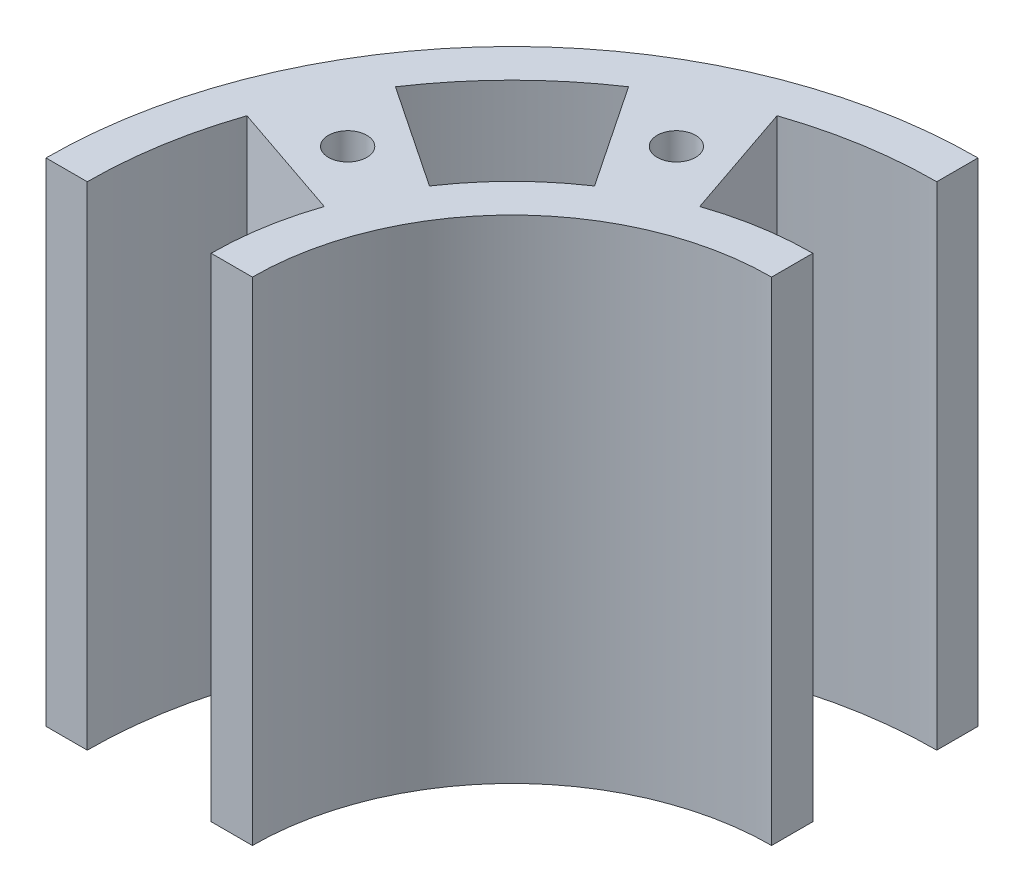
from build123d import *

# Parameters (mm, degrees)
SKETCH2_R           = 1.825
BOSS_EXTRUDE2_DEPTH = 46.8


with BuildPart() as part:
    # Sketch2 → Boss-Extrude2 (new body)
    with BuildSketch(Plane(origin=(0, 0, 0), x_dir=(1, 0, 0), z_dir=(0, 1, 0))):
        with BuildLine():
            Line((31.4, -60), (35.32, -60))
            ThreePointArc((35.32, -60), (42.54860464, -42.54860464), (60, -35.32))
            Line((60, -35.32), (60, -31.4))
            ThreePointArc((60, -31.4), (55.324247919, -31.784802987), (50.774317053, -32.928857169))
            Line((50.774317053, -32.928857169), (46.974367923, -21.778575262))
            ThreePointArc((46.974367923, -21.778575262), (53.398361223, -20.163298763), (60, -19.62))
            Line((60, -19.62), (60, -15.7))
            ThreePointArc((60, -15.7), (28.675169593, -28.675169593), (15.7, -60))
            Line((15.7, -60), (19.62, -60))
            ThreePointArc((19.62, -60), (20.163298763, -53.398361223), (21.778575262, -46.974367923))
            Line((21.778575262, -46.974367923), (32.928857169, -50.774317053))
            ThreePointArc((32.928857169, -50.774317053), (31.784802987, -55.324247919), (31.4, -60))
        make_face()
        with BuildLine():
            Line((37.529399815, -26.449790949), (44.084716065, -36.237345744))
            ThreePointArc((44.084716065, -36.237345744), (39.776746058, -39.776746058), (36.237345744, -44.084716065))
            Line((36.237345744, -44.084716065), (26.449790949, -37.529399815))
            ThreePointArc((26.449790949, -37.529399815), (31.447028176, -31.447028176), (37.529399815, -26.449790949))
        make_face(mode=Mode.SUBTRACT)
        with Locations((29.084372884, -44.71)):
            Circle(SKETCH2_R, mode=Mode.SUBTRACT)
        with Locations((44.71, -29.084372884)):
            Circle(SKETCH2_R, mode=Mode.SUBTRACT)
    extrude(amount=BOSS_EXTRUDE2_DEPTH)


solid = part.part
